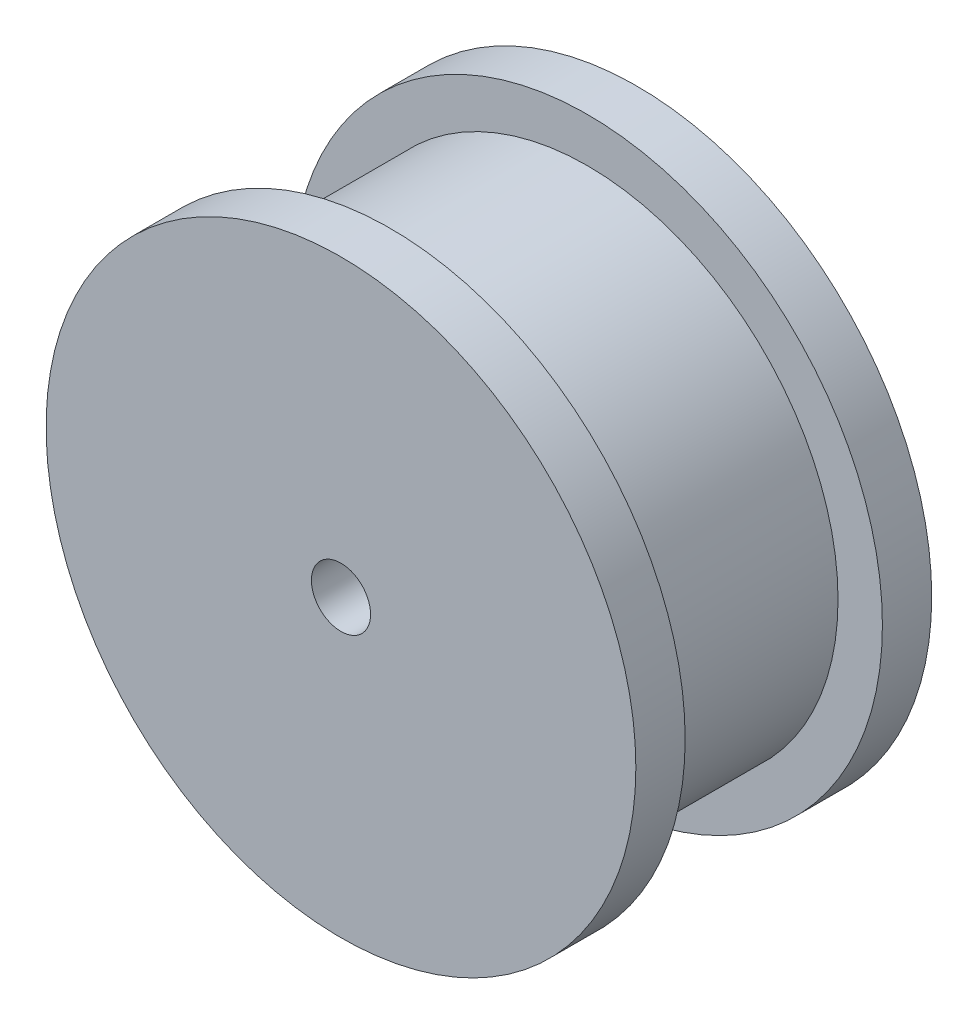
from build123d import *

# Parameters (mm, degrees)
SKETCH1_R           = 25.4
BOSS_EXTRUDE1_DEPTH = 10
SKETCH2_R           = 29.9
BOSS_EXTRUDE2_DEPTH = 5
SKETCH3_R           = 3
CUT_EXTRUDE1_DEPTH  = 76.628


with BuildPart() as part:
    # Sketch1 → Boss-Extrude1 (new body, symmetric)
    with BuildSketch(Plane.XY):
        Circle(SKETCH1_R)
    extrude(amount=BOSS_EXTRUDE1_DEPTH, both=True)

    # Sketch2 → Boss-Extrude2 (add)
    with BuildSketch(Plane.XY.offset(10)):
        Circle(SKETCH2_R)
    boss_extrude2 = extrude(amount=BOSS_EXTRUDE2_DEPTH)

    # Mirror1: Boss-Extrude2 across plane
    add(boss_extrude2.mirror(Plane.XY))

    # Sketch3 → Cut-Extrude1 (cut)
    with BuildSketch(Plane.XY.offset(15)):
        Circle(SKETCH3_R)
    extrude(amount=-CUT_EXTRUDE1_DEPTH, mode=Mode.SUBTRACT)


solid = part.part
